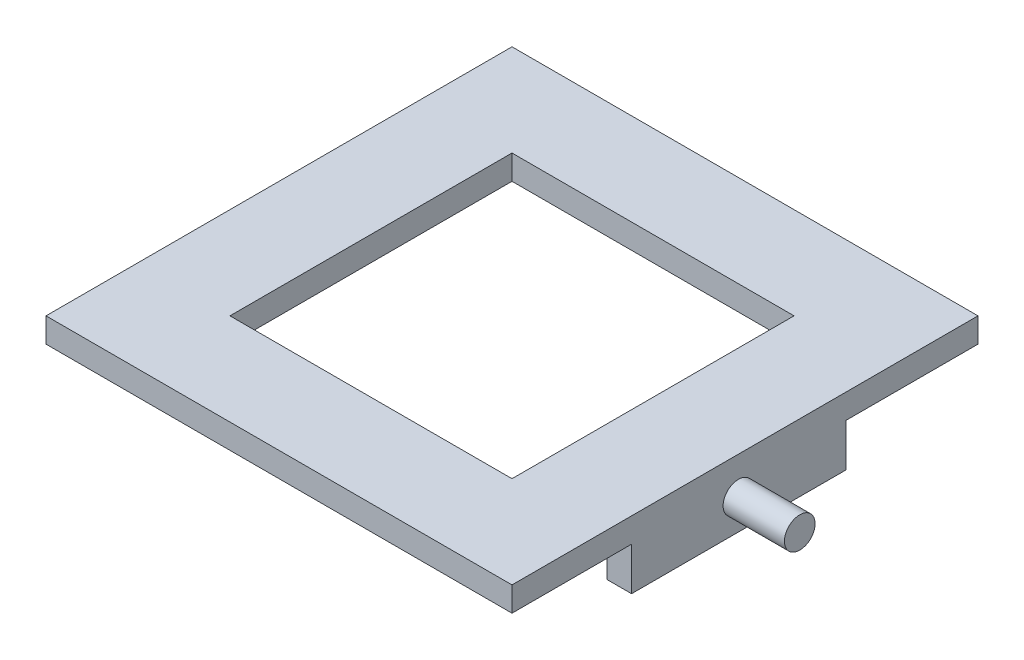
from build123d import *

# Parameters (mm, degrees)
SKETCH1_W             = 76
SKETCH1_H             = 76
SKETCH1_W_2           = 46
SKETCH1_H_2           = 46
BOSS_EXTRUDE2_DEPTH   = 4
SKETCH7_R             = 0.6
BOSS_EXTRUDE5_DEPTH   = 2
BOSS_EXTRUDE5_2_DEPTH = 2
SKETCH8_W             = 35
SKETCH8_H             = 11
BOSS_EXTRUDE6_DEPTH   = 4
SKETCH9_W             = 35
SKETCH9_H             = 11
BOSS_EXTRUDE7_DEPTH   = 4
SKETCH10_R            = 2.5
BOSS_EXTRUDE8_DEPTH   = 10


with BuildPart() as part:
    # Sketch1 → Boss-Extrude2 (new body)
    with BuildSketch(Plane(origin=(0, 0, 0), x_dir=(1, 0, 0), z_dir=(0, 1, 0))):
        with Locations((38, 38)):
            Rectangle(SKETCH1_W, SKETCH1_H)
        with Locations((38, 38)):
            Rectangle(SKETCH1_W_2, SKETCH1_H_2, mode=Mode.SUBTRACT)
    extrude(amount=BOSS_EXTRUDE2_DEPTH)



with BuildPart() as body_2:
    # Sketch7 → Boss-Extrude5 (new body)
    with BuildSketch(Plane.ZY):
        with Locations((-51.45, -2.06)):
            Circle(SKETCH7_R)
    extrude(amount=BOSS_EXTRUDE5_DEPTH)


with BuildPart() as body_3:
    # Sketch7 → Boss-Extrude5 2 (new body)
    with BuildSketch(Plane.ZY):
        with Locations((-22.55, -2.06)):
            Circle(SKETCH7_R)
    extrude(amount=BOSS_EXTRUDE5_2_DEPTH)


with BuildPart() as part_1:
    add(part.part)

    add(body_2.part)  # Boss-Extrude6 merges body 2

    add(body_3.part)  # Boss-Extrude6 merges body 3
    # Sketch8 → Boss-Extrude6 (add)
    with BuildSketch(Plane.ZY):
        with Locations((-37, -1.5)):
            Rectangle(SKETCH8_W, SKETCH8_H)
    extrude(amount=-BOSS_EXTRUDE6_DEPTH)

    # Sketch9 → Boss-Extrude7 (add)
    with BuildSketch(Plane(origin=(76, 0, 0), x_dir=(0, 0, -1), z_dir=(1, 0, 0))):
        with Locations((37, -1.5)):
            Rectangle(SKETCH9_W, SKETCH9_H)
    extrude(amount=-BOSS_EXTRUDE7_DEPTH)

    # Sketch10 → Boss-Extrude8 (add)
    with BuildSketch(Plane(origin=(76, 0, 0), x_dir=(0, 0, -1), z_dir=(1, 0, 0))):
        with Locations((36.93, -2.06)):
            Circle(SKETCH10_R)
    extrude(amount=BOSS_EXTRUDE8_DEPTH)


solid = part_1.part
